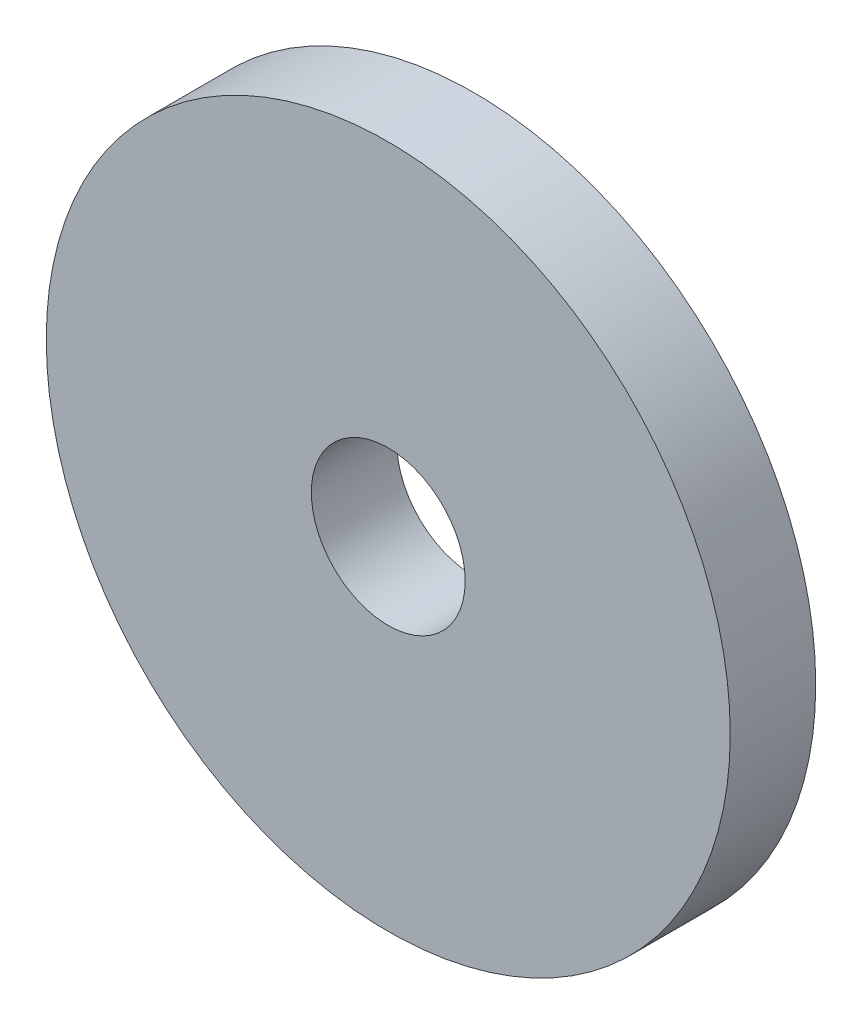
from build123d import *

# Parameters (mm, degrees)
SKETCH2_R           = 20
SKETCH2_R_2         = 4.5
BOSS_EXTRUDE1_DEPTH = 2.5


with BuildPart() as part:
    # Sketch2 → Boss-Extrude1 (new body, symmetric)
    with BuildSketch(Plane.XY):
        Circle(SKETCH2_R)
        Circle(SKETCH2_R_2, mode=Mode.SUBTRACT)
    extrude(amount=BOSS_EXTRUDE1_DEPTH, both=True)


solid = part.part
